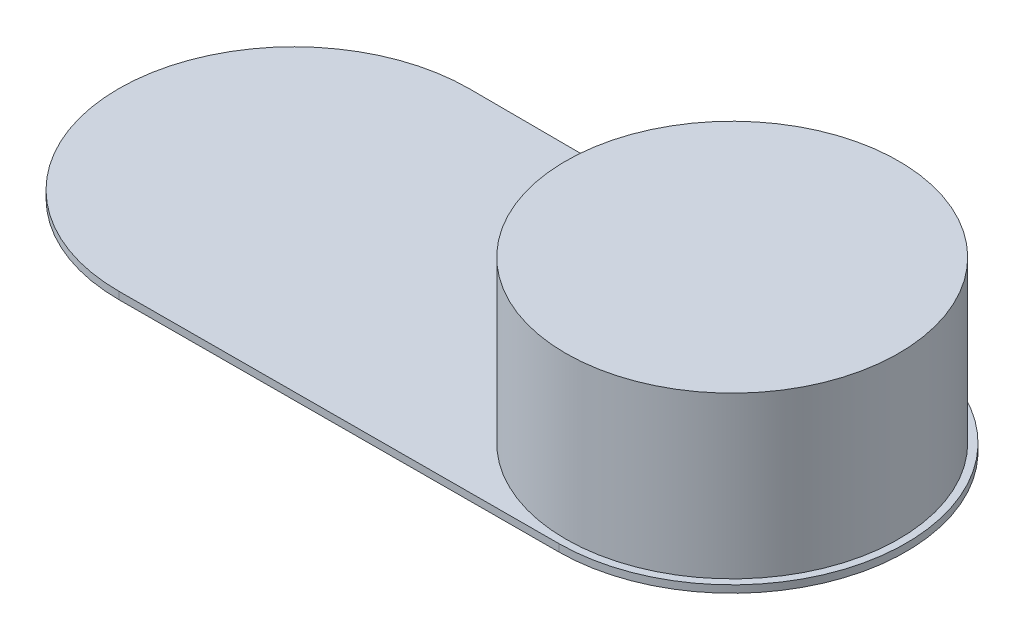
from build123d import *

# Parameters (mm, degrees)
SKETCH1_R           = 109
BOSS_EXTRUDE1_DEPTH = 5
SKETCH2_R           = 114
SKETCH2_R_2         = 109
BOSS_EXTRUDE2_DEPTH = 105.1
SKETCH3_R           = 114
BOSS_EXTRUDE3_DEPTH = 5


with BuildPart() as part:
    # Sketch1 → Boss-Extrude1 (new body)
    with BuildSketch(Plane(origin=(0, 0, 0), x_dir=(1, 0, 0), z_dir=(0, 1, 0))):
        with BuildLine():
            Line((-299.6, 119.999333331), (0.396666667, 118.999338887))
            ThreePointArc((0.396666667, 118.999338887), (119, 0), (0.396666667, -118.999338887))
            Line((0.396666667, -118.999338887), (-299.6, -119.999333331))
            ThreePointArc((-299.6, -119.999333331), (-420, 0), (-299.6, 119.999333331))
        make_face()
        with BuildLine():
            ThreePointArc((0.38, -113.999366665), (114, 0), (0.38, 113.999366665))
            Line((0.38, 113.999366665), (-299.616666667, 114.999361109))
            ThreePointArc((-299.616666667, 114.999361109), (-415, 0), (-299.616666667, -114.999361109))
            Line((-299.616666667, -114.999361109), (0.38, -113.999366665))
        make_face(mode=Mode.SUBTRACT)
        with BuildLine():
            Line((0.38, -113.999366665), (-299.616666667, -114.999361109))
            ThreePointArc((-299.616666667, -114.999361109), (-415, 0), (-299.616666667, 114.999361109))
            Line((-299.616666667, 114.999361109), (0.38, 113.999366665))
            ThreePointArc((0.38, 113.999366665), (114, 0), (0.38, -113.999366665))
        make_face()
        with Locations(Location((0, 0, 0), (0, 0, 270))):
            Circle(SKETCH1_R, mode=Mode.SUBTRACT)
    extrude(amount=BOSS_EXTRUDE1_DEPTH)

    # Sketch2 → Boss-Extrude2 (add)
    with BuildSketch(Plane(origin=(0, 5, 0), x_dir=(1, 0, 0), z_dir=(0, 1, 0))):
        with Locations(Location((0, 0, 0), (0, 0, 270))):
            Circle(SKETCH2_R)
        with Locations(Location((0, 0, 0), (0, 0, 270))):
            Circle(SKETCH2_R_2, mode=Mode.SUBTRACT)
    extrude(amount=BOSS_EXTRUDE2_DEPTH)

    # Sketch3 → Boss-Extrude3 (add)
    with BuildSketch(Plane(origin=(0, 110.1, 0), x_dir=(1, 0, 0), z_dir=(0, 1, 0))):
        with Locations(Location((0, 0, 0), (0, 0, 270))):
            Circle(SKETCH3_R)
    extrude(amount=BOSS_EXTRUDE3_DEPTH)


solid = part.part
